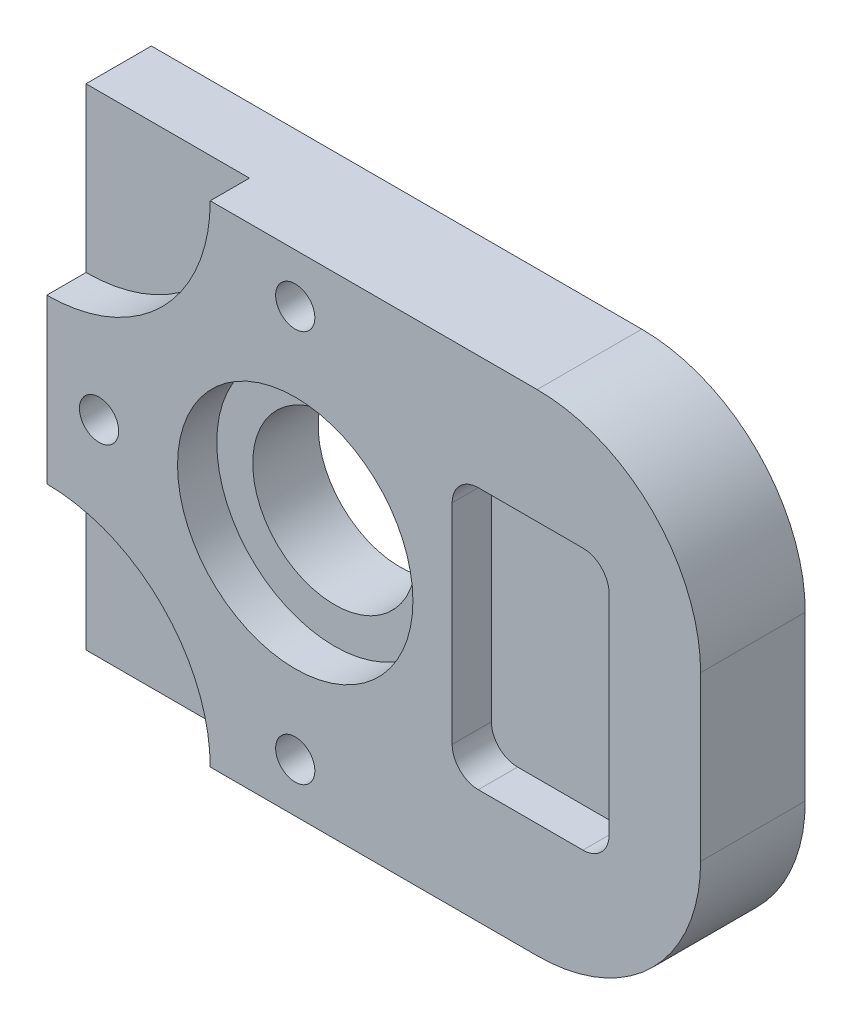
from build123d import *

# Parameters (mm, degrees)
EXTRUDE1_DEPTH     = 16
SKETCH2_R          = 12.5
CUT_EXTRUDE1_DEPTH = 17
SKETCH3_R          = 18
CUT_EXTRUDE2_DEPTH = 6
SKETCH4_W          = 24
SKETCH4_H          = 40
CUT_EXTRUDE3_DEPTH = 6
FILLET1_R          = 4
HOLE1_D            = 6
SKETCH7_R          = 25
CUT_EXTRUDE4_DEPTH = 6


with BuildPart() as part:
    # Sketch1 → Extrude1 (new body)
    with BuildSketch(Plane.XY):
        with BuildLine():
            Line((0, 75), (75, 75))
            ThreePointArc((75, 75), (92.67766953, 67.67766953), (100, 50))
            Line((100, 50), (100, 25))
            ThreePointArc((100, 25), (92.67766953, 7.32233047), (75, 0))
            Line((75, 0), (0, 0))
            Line((0, 0), (0, 75))
        make_face()
    extrude(amount=EXTRUDE1_DEPTH)

    # Sketch2 → Cut-Extrude1 (cut, through all)
    with BuildSketch(Plane.XY.offset(16)):
        with Locations((38, 37.5)):
            Circle(SKETCH2_R)
    extrude(amount=-CUT_EXTRUDE1_DEPTH, mode=Mode.SUBTRACT)

    # Sketch3 → Cut-Extrude2 (cut)
    with BuildSketch(Plane.XY.offset(16)):
        with Locations((38, 37.5)):
            Circle(SKETCH3_R)
    extrude(amount=-CUT_EXTRUDE2_DEPTH, mode=Mode.SUBTRACT)

    # Sketch4 → Cut-Extrude3 (cut)
    with BuildSketch(Plane.XY.offset(16)):
        with Locations((74, 37.5)):
            Rectangle(SKETCH4_W, SKETCH4_H)
    extrude(amount=-CUT_EXTRUDE3_DEPTH, mode=Mode.SUBTRACT)

    # Fillet1
    fillet1_edges = [part.edges().sort_by_distance(p)[0] for p in [
        (62, 17.5, 13),
        (62, 57.5, 13),
        (86, 57.5, 13),
        (86, 17.5, 13),
    ]]
    fillet(fillet1_edges, radius=FILLET1_R)

    # Hole1 (through all)
    with Locations(Plane.XY.offset(16)):
        with Locations((38, 67.5), (8, 37.5), (38, 7.5)):
            Hole(HOLE1_D / 2)

    # Sketch7 → Cut-Extrude4 (cut)
    with BuildSketch(Plane.XY.offset(16)):
        with Locations((0, 75)):
            Circle(SKETCH7_R)
        Circle(SKETCH7_R)
    extrude(amount=-CUT_EXTRUDE4_DEPTH, mode=Mode.SUBTRACT)


solid = part.part
